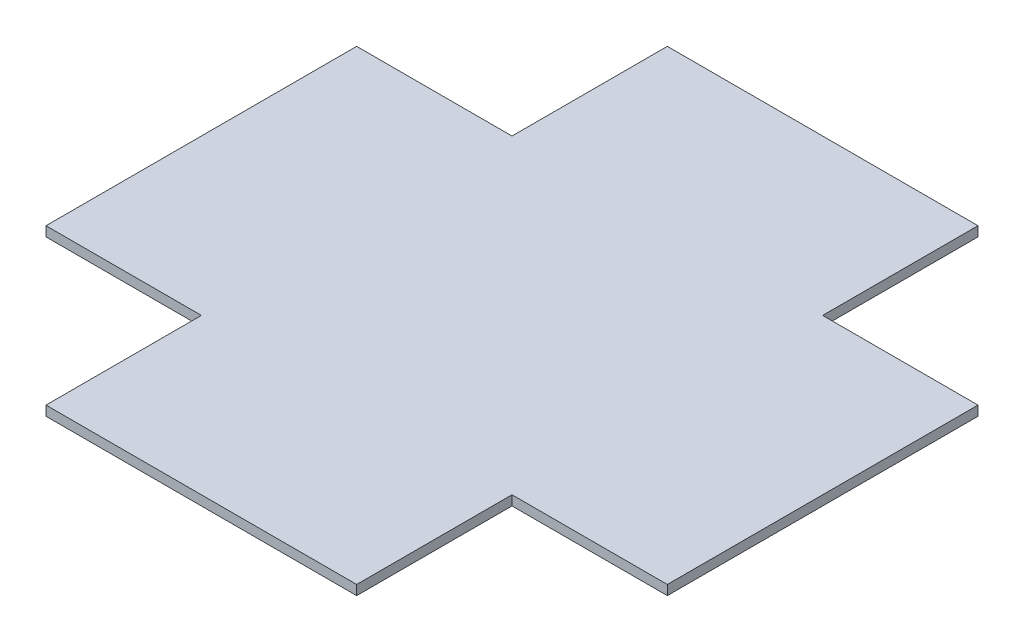
from build123d import *

# Parameters (mm, degrees)
BOSS_EXTRUDE1_DEPTH = 1.5875


with BuildPart() as part:
    # Sketch1 → Boss-Extrude1 (new body)
    with BuildSketch(Plane(origin=(0, 0, 0), x_dir=(1, 0, 0), z_dir=(0, 1, 0))):
        Polygon((-25.4, 50.8), (-25.4, 25.4), (-50.8, 25.4), (-50.8, -25.4), (-25.4, -25.4), (-25.4, -50.8), (25.4, -50.8), (25.4, -25.4), (50.8, -25.4), (50.8, 25.4), (25.4, 25.4), (25.4, 50.8), align=None)
    extrude(amount=BOSS_EXTRUDE1_DEPTH)


solid = part.part
